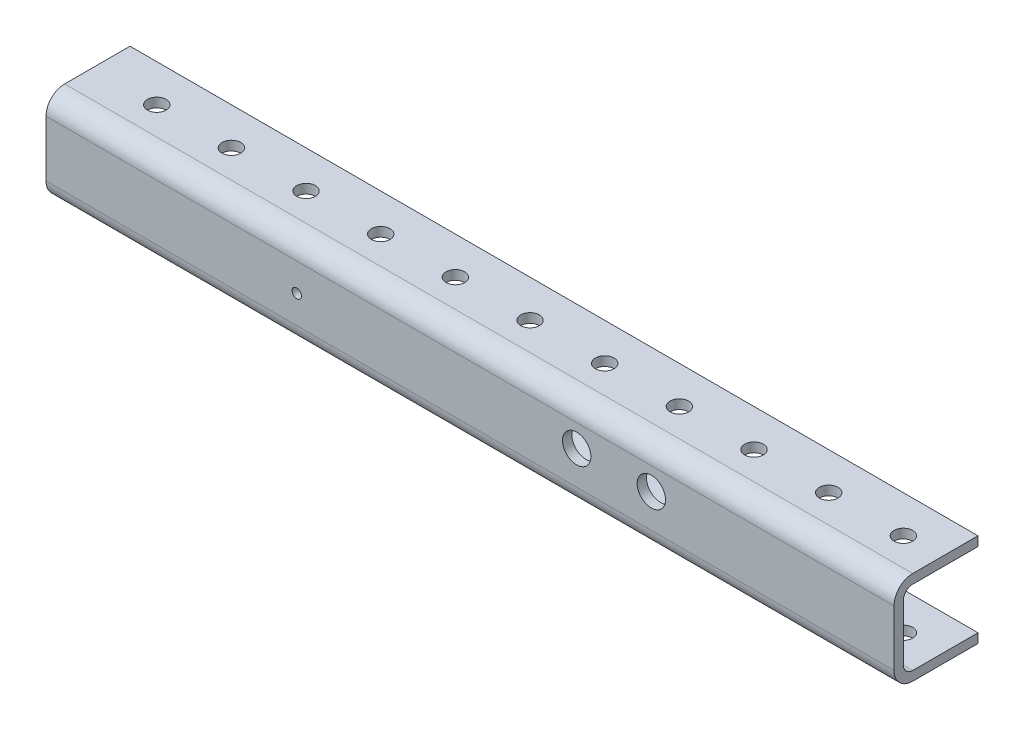
from build123d import *

# Parameters (mm, degrees)
SKETCH1_W          = 889
SKETCH1_H          = 31.75
EXTRUDE1_DEPTH     = 28.575
EXTRUDE2_REACH     = 891.702
SKETCH2_W          = 25.4
SKETCH2_H          = 25.4
HOLE1_D            = 6.35
HOLE1_DEPTH        = 3.175
LPATTERN1_COUNT    = 35
LPATTERN1_PITCH    = 25.4
HOLE2_D            = 9.652
LPATTERN2_COUNT    = 12
LPATTERN2_PITCH    = 25.4
HOLE3_D            = 9.652
HOLE4_D            = 9.652
LPATTERN3_COUNT    = 12
LPATTERN3_PITCH    = 25.4
HOLE5_D            = 3.175
HOLE6_D            = 6.35
LPATTERN4_COUNT    = 35
LPATTERN4_PITCH    = 25.4
FILLET1_R          = 3.175
FILLET2_R          = 3.175
FILLET3_R          = 6.35
FILLET4_R          = 6.35
SKETCH16_W         = 145.760071232
SKETCH16_H         = 71.504803879
CUT_EXTRUDE2_DEPTH = 75
SKETCH17_W         = 473.628565651
SKETCH17_H         = 66.908943447
CUT_EXTRUDE3_DEPTH = 186
SKETCH18_W         = 75.554715297
SKETCH18_H         = 79.695835758
CUT_EXTRUDE4_DEPTH = 874.792443416


with BuildPart() as part:
    # Sketch1 → Extrude1 (new body)
    with BuildSketch(Plane.XY.offset(3.175)):
        with Locations((428.480011997, 8.672957166)):
            Rectangle(SKETCH1_W, SKETCH1_H)
    extrude(amount=-EXTRUDE1_DEPTH)

    # Sketch2 → Extrude2 (cut, up to next)
    with BuildSketch(Plane.ZY.offset(16.019988003), mode=Mode.PRIVATE) as extrude2_sk1:
        with Locations((-12.7, 8.672957166)):
            Rectangle(SKETCH2_W, SKETCH2_H)
    extrude2_tool1 = extrude(extrude2_sk1.sketch, amount=-EXTRUDE2_REACH, mode=Mode.PRIVATE) & part.part
    add(extrude2_tool1.solids().sort_by_distance((-16.019988, 8.672957, -12.7))[0], mode=Mode.SUBTRACT)

    # Hole1
    with Locations(Plane(origin=(0, 24.547957166, 0), x_dir=(-1, 0, 0), z_dir=(0, 1, 0))):
        with Locations((3.319988003, -12.7)):
            hole1 = Hole(HOLE1_D / 2, depth=HOLE1_DEPTH)

    # LPattern1: Hole1 ×35
    with Locations(*[(i * LPATTERN1_PITCH, 0, 0) for i in range(1, LPATTERN1_COUNT)]):
        add(hole1, mode=Mode.SUBTRACT)

    # Hole2 (through all)
    with Locations(Plane.XY.offset(3.175)):
        with Locations((66.530011997, 10.577957166)):
            hole2 = Hole(HOLE2_D / 2)

    # LPattern2: Hole2 ×12, 8 skipped
    with Locations(*[(i * LPATTERN2_PITCH, 0, 0) for i in range(1, LPATTERN2_COUNT) if i not in (2, 3, 4, 5, 6, 7, 8, 9)]):
        add(hole2, mode=Mode.SUBTRACT)

    # Hole3 (through all)
    with Locations(Plane.XY.offset(3.175)):
        with Locations((428.480011997, 6.767957166)):
            Hole(HOLE3_D / 2)

    # Hole4 (through all)
    with Locations(Plane.XY.offset(3.175)):
        with Locations((511.030011997, 10.577957166)):
            hole4 = Hole(HOLE4_D / 2)

    # LPattern3: Hole4 ×12, 8 skipped
    with Locations(*[(i * LPATTERN3_PITCH, 0, 0) for i in range(1, LPATTERN3_COUNT) if i not in (2, 3, 4, 5, 6, 7, 8, 9)]):
        add(hole4, mode=Mode.SUBTRACT)

    # Hole5 (through all)
    with Locations(Plane.XY.offset(3.175)):
        with Locations((669.780011997, 8.672957166)):
            Hole(HOLE5_D / 2)

    # Hole6 (through all)
    with Locations(Plane(origin=(0, -4.027042834, 0), x_dir=(-1, 0, 0), z_dir=(0, 1, 0))):
        with Locations((3.319988003, -12.7)):
            hole6 = Hole(HOLE6_D / 2)

    # LPattern4: Hole6 ×35
    with Locations(*[(i * LPATTERN4_PITCH, 0, 0) for i in range(1, LPATTERN4_COUNT)]):
        add(hole6, mode=Mode.SUBTRACT)

    # Fillet1
    fillet1_edges = [part.edges().sort_by_distance(p)[0] for p in [
        (428.480011997, 21.372957166, 0),
    ]]
    fillet(fillet1_edges, radius=FILLET1_R)

    # Fillet2
    fillet2_edges = [part.edges().sort_by_distance(p)[0] for p in [
        (428.480011997, -4.027042834, 0),
    ]]
    fillet(fillet2_edges, radius=FILLET2_R)

    # Fillet3
    fillet3_edges = [part.edges().sort_by_distance(p)[0] for p in [
        (428.480011997, -7.202042834, 3.175),
    ]]
    fillet(fillet3_edges, radius=FILLET3_R)

    # Fillet4
    fillet4_edges = [part.edges().sort_by_distance(p)[0] for p in [
        (428.480011997, 24.547957166, 3.175),
    ]]
    fillet(fillet4_edges, radius=FILLET4_R)

    # Sketch16 → Cut-Extrude2 (cut)
    with BuildSketch(Plane(origin=(0, 24.547957166, 0), x_dir=(1, 0, 0), z_dir=(0, 1, 0))):
        with Locations((40.099976381, -10.352401939)):
            Rectangle(SKETCH16_W, SKETCH16_H)
    extrude(amount=-CUT_EXTRUDE2_DEPTH, mode=Mode.SUBTRACT)

    # Sketch17 → Cut-Extrude3 (cut)
    with BuildSketch(Plane(origin=(0, 24.547957166, 0), x_dir=(1, 0, 0), z_dir=(0, 1, 0))):
        with Locations((288.165729172, -8.054471723)):
            Rectangle(SKETCH17_W, SKETCH17_H)
    extrude(amount=-CUT_EXTRUDE3_DEPTH, mode=Mode.SUBTRACT)

    # Sketch18 → Cut-Extrude4 (cut, through all)
    with BuildSketch(Plane.XY.offset(3.175)):
        with Locations((546.702654349, 2.856578578)):
            Rectangle(SKETCH18_W, SKETCH18_H)
    extrude(amount=-CUT_EXTRUDE4_DEPTH, mode=Mode.SUBTRACT)


solid = part.part
